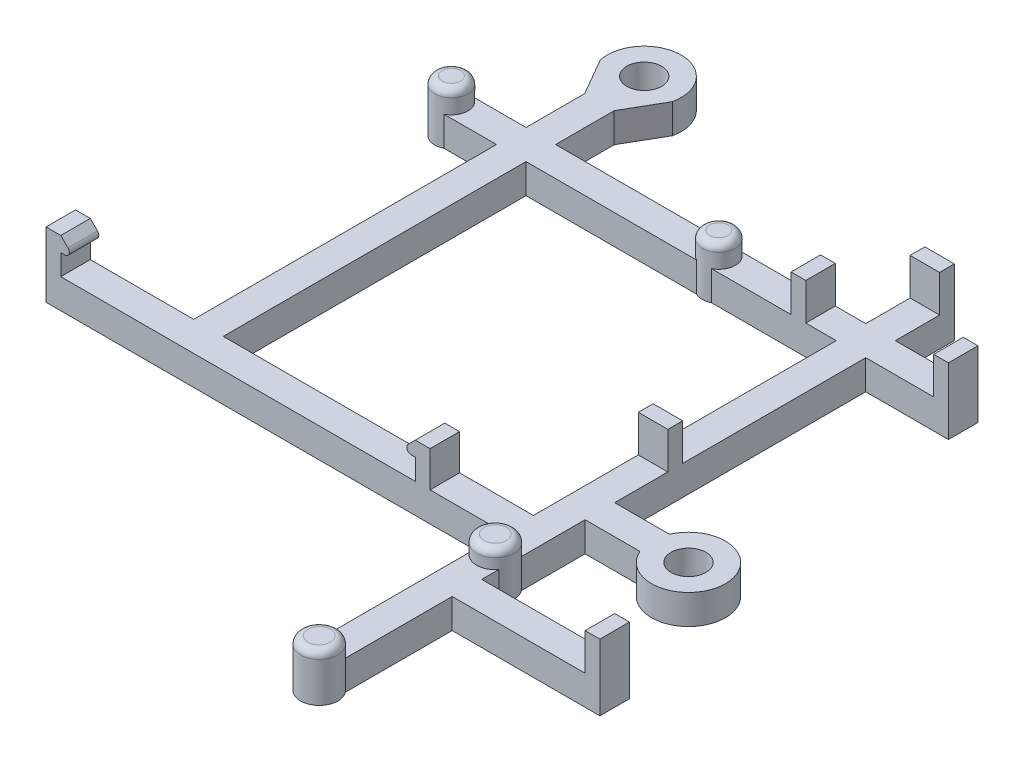
from build123d import *

# Parameters (mm, degrees)
SKETCH1_R                = 1.5
SKETCH1_W                = 26.67
SKETCH1_H                = 26.035
BOSS_EXTRUDE1_DEPTH      = 2.54
SKETCH3_W                = 1.27
SKETCH3_H                = 3.175
BOSS_EXTRUDE3_DEPTH      = 2.54
BOSS_EXTRUDE4_DEPTH      = 2.54
SKETCH5_W                = 1.27
SKETCH5_H                = 3.175
BOSS_EXTRUDE5_DEPTH      = 2.54
SKETCH7_W                = 1.27
SKETCH7_H                = 3.175
BOSS_EXTRUDE6_DEPTH      = 2.54
FILLET1_R                = 0.381
CUT_EXTRUDE2_REACH       = 16.605
SKETCH11_W               = 4.50557805
SKETCH11_H               = 5.61
SKETCH11_W_2             = 2.400870557
SKETCH11_H_2             = 3.07
SKETCH8_R                = 1.4224
BOSS_EXTRUDE7_DEPTH      = 1.905
BOSS_EXTRUDE7_DEPTH_BACK = 2.54
SKETCH10_R               = 1.6002
BOSS_EXTRUDE8_DEPTH      = 1.524
BOSS_EXTRUDE8_DEPTH_BACK = 2.54
FILLET2_R                = 0.635


with BuildPart() as part:
    # Sketch1 → Boss-Extrude1 (new body)
    with BuildSketch(Plane(origin=(0, 0, 0), x_dir=(1, 0, 0), z_dir=(0, 1, 0))):
        with BuildLine():
            Line((-10.16, -22.86), (-10.16, -5.715))
            Line((-10.16, -5.715), (-49.53, -5.715))
            Line((-49.53, -5.715), (-49.53, -3.175))
            Line((-49.53, -3.175), (-39.37, -3.175))
            Line((-39.37, -3.175), (-39.37, 22.86))
            Line((-39.37, 22.86), (-49.53, 22.86))
            Line((-49.53, 22.86), (-49.53, 25.4))
            Line((-49.53, 25.4), (-39.37, 25.4))
            Line((-39.37, 25.4), (-39.37, 30.443080793))
            Line((-39.37, 30.443080793), (-41.203087105, 33.618080793))
            ThreePointArc((-41.203087105, 33.618080793), (-38.1, 37.465), (-34.996912895, 33.618080793))
            Line((-34.996912895, 33.618080793), (-36.83, 30.443080793))
            Line((-36.83, 30.443080793), (-36.83, 25.4))
            Line((-36.83, 25.4), (-10.16, 25.4))
            Line((-10.16, 25.4), (-10.16, 30.48))
            Line((-10.16, 30.48), (-7.62, 30.48))
            Line((-7.62, 30.48), (-7.62, 25.4))
            Line((-7.62, 25.4), (-0.508, 25.4))
            Line((-0.508, 25.4), (-0.508, 22.86))
            Line((-0.508, 22.86), (-7.62, 22.86))
            Line((-7.62, 22.86), (-7.62, 1.27))
            Line((-7.62, 1.27), (-2.909935566, 1.27))
            ThreePointArc((-2.909935566, 1.27), (3.175, 0), (-2.909935566, -1.27))
            Line((-2.909935566, -1.27), (-7.62, -1.27))
            Line((-7.62, -1.27), (-7.62, -10.16))
            Line((-7.62, -10.16), (5.08, -10.16))
            Line((5.08, -10.16), (5.08, -12.7))
            Line((5.08, -12.7), (-7.62, -12.7))
            Line((-7.62, -12.7), (-7.62, -22.86))
            Line((-7.62, -22.86), (-10.16, -22.86))
        make_face()
        with Locations((-38.1, 34.29)):
            Circle(SKETCH1_R, mode=Mode.SUBTRACT)
        Circle(SKETCH1_R, mode=Mode.SUBTRACT)
        with Locations((-23.495, 9.8425)):
            Rectangle(SKETCH1_W, SKETCH1_H, mode=Mode.SUBTRACT)
    extrude(amount=BOSS_EXTRUDE1_DEPTH)

    # Sketch3 → Boss-Extrude3 (add)
    with BuildSketch(Plane.XY.offset(-22.86)):
        Polygon((-49.53, 2.54), (-49.53, 5.61), (-48.26, 5.61), (-46.99, 4.34), (-48.26, 4.34), (-48.26, 2.54), align=None)
        with Locations((-1.143, 4.1275)):
            Rectangle(SKETCH3_W, SKETCH3_H)
        Polygon((-16.51, 2.54), (-17.78, 2.54), (-17.78, 4.34), (-19.05, 4.34), (-17.78, 5.61), (-16.51, 5.61), align=None)
        with Locations((-13.4112, 4.1275)):
            Rectangle(SKETCH3_W, SKETCH3_H)
    extrude(amount=-BOSS_EXTRUDE3_DEPTH)

    # Sketch4 → Boss-Extrude4 (add)
    with BuildSketch(Plane.XY.offset(5.715)):
        Polygon((-17.78, 2.54), (-16.51, 2.54), (-16.51, 5.61), (-17.78, 5.61), (-19.05, 4.34), (-17.78, 4.34), align=None)
        Polygon((-49.53, 2.54), (-48.26, 2.54), (-48.26, 4.34), (-46.99, 4.34), (-48.26, 5.61), (-49.53, 5.61), align=None)
    extrude(amount=-BOSS_EXTRUDE4_DEPTH)

    # Sketch5 → Boss-Extrude5 (add)
    with BuildSketch(Plane(origin=(-7.62, 0, 0), x_dir=(0, 0, -1), z_dir=(1, 0, 0))):
        with Locations((6.477, 4.1275)):
            Rectangle(SKETCH5_W, SKETCH5_H)
        with Locations((29.845, 4.1275)):
            Rectangle(SKETCH5_W, SKETCH5_H)
    extrude(amount=-BOSS_EXTRUDE5_DEPTH)

    # Sketch7 → Boss-Extrude6 (add)
    with BuildSketch(Plane.XY.offset(12.7)):
        with Locations((4.445, 4.1275)):
            Rectangle(SKETCH7_W, SKETCH7_H)
    extrude(amount=-BOSS_EXTRUDE6_DEPTH)

    # Fillet1
    fillet1_edges = [part.edges().sort_by_distance(p)[0] for p in [
        (-46.99, 4.34, -24.13),
        (-19.05, 4.34, -24.13),
        (-46.99, 4.34, 4.445),
        (-19.05, 4.34, 4.445),
    ]]
    fillet(fillet1_edges, radius=FILLET1_R)

    # Sketch11 → Cut-Extrude2 (cut, up to next)
    with BuildSketch(Plane.XY.offset(-22.86), mode=Mode.PRIVATE) as cut_extrude2_sk1:
        with Locations((-47.277210975, 2.805)):
            Rectangle(SKETCH11_W, SKETCH11_H)
    cut_extrude2_tool1 = extrude(cut_extrude2_sk1.sketch, amount=-CUT_EXTRUDE2_REACH, mode=Mode.PRIVATE) & part.part
    add(cut_extrude2_tool1.solids().sort_by_distance((-47.277211, 2.805, -22.86))[0], mode=Mode.SUBTRACT)
    # Sketch11 → Cut-Extrude2 (cut, up to next)
    with BuildSketch(Plane.XY.offset(-22.86), mode=Mode.PRIVATE) as cut_extrude2_sk2:
        with Locations((-17.710435279, 4.075)):
            Rectangle(SKETCH11_W_2, SKETCH11_H_2)
    cut_extrude2_tool2 = extrude(cut_extrude2_sk2.sketch, amount=-CUT_EXTRUDE2_REACH, mode=Mode.PRIVATE) & part.part
    add(cut_extrude2_tool2.solids().sort_by_distance((-17.710435, 4.075, -22.86))[0], mode=Mode.SUBTRACT)

    # Sketch8 → Boss-Extrude7 (add, two sides)
    with BuildSketch(Plane(origin=(0, 2.54, 0), x_dir=(1, 0, 0), z_dir=(0, 1, 0))) as boss_extrude7_sk:
        with Locations((-44.52, 24.13)):
            Circle(SKETCH8_R)
        with Locations((-21.52, 24.13)):
            Circle(SKETCH8_R)
    extrude(amount=BOSS_EXTRUDE7_DEPTH)
    extrude(boss_extrude7_sk.sketch, amount=-BOSS_EXTRUDE7_DEPTH_BACK)

    # Sketch10 → Boss-Extrude8 (add, two sides)
    with BuildSketch(Plane(origin=(0, 2.54, 0), x_dir=(1, 0, 0), z_dir=(0, 1, 0))) as boss_extrude8_sk:
        with Locations((-8.89, -7.7216)):
            Circle(SKETCH10_R)
        with Locations((-8.89, -22.86)):
            Circle(SKETCH10_R)
    extrude(amount=BOSS_EXTRUDE8_DEPTH)
    extrude(boss_extrude8_sk.sketch, amount=-BOSS_EXTRUDE8_DEPTH_BACK)

    # Fillet2
    fillet2_edges = [part.edges().sort_by_distance(p)[0] for p in [
        (-45.9424, 4.445, -24.13),
        (-22.9424, 4.445, -24.13),
        (-10.4902, 4.064, 7.7216),
        (-10.4902, 4.064, 22.86),
    ]]
    fillet(fillet2_edges, radius=FILLET2_R)


solid = part.part
